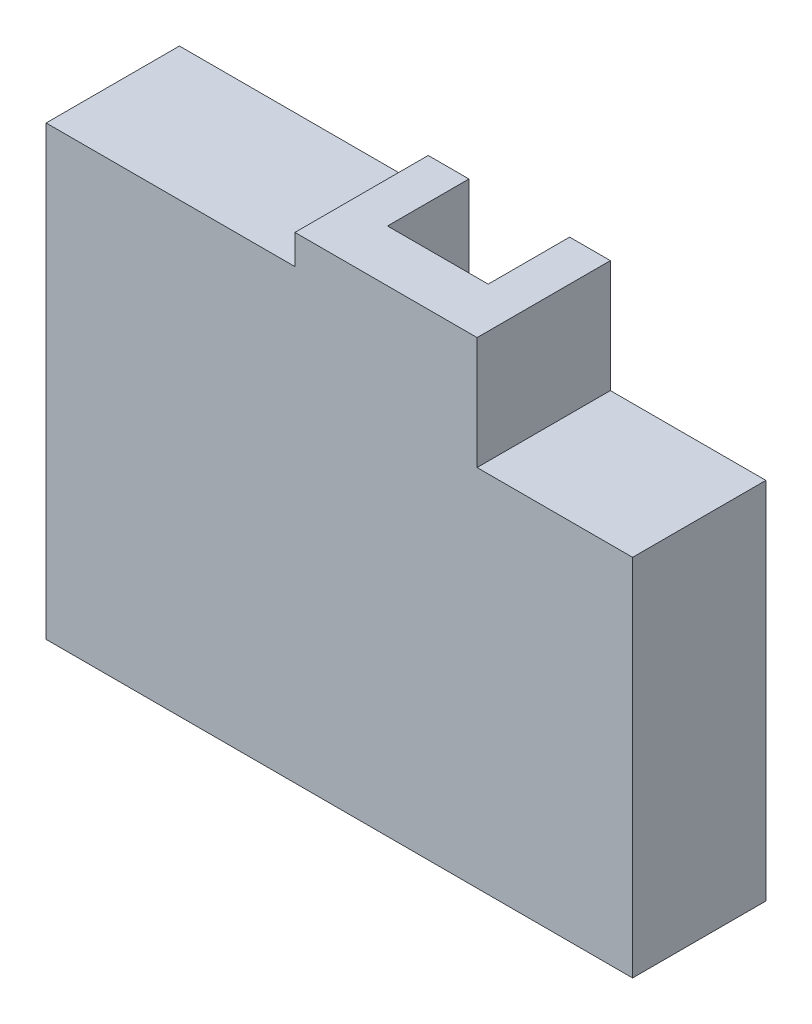
from build123d import *

# Parameters (mm, degrees)
BOSS_EXTRUDE3_DEPTH = 3
BOSS_EXTRUDE4_DEPTH = 15
CUT_EXTRUDE1_DEPTH  = 3
CUT_EXTRUDE2_DEPTH  = 3
SKETCH4_W           = 13.6
SKETCH4_H           = 11
CUT_EXTRUDE3_DEPTH  = 3
CUT_EXTRUDE4_DEPTH  = 3


with BuildPart() as part:
    # Sketch1 → Boss-Extrude3 (new body)
    with BuildSketch(Plane.XY):
        Polygon((0, 0), (79.2, 0), (79.2, 49.2), (58.2, 49.2), (58.2, 64.4), (33.6, 64.4), (33.6, 60.4), (0, 60.4), align=None)
    extrude(amount=BOSS_EXTRUDE3_DEPTH)

    # Sketch1_9 → Boss-Extrude4 (add)
    with BuildSketch(Plane.XY):
        Polygon((0, 0), (79.2, 0), (79.2, 49.2), (58.2, 49.2), (58.2, 64.4), (33.6, 64.4), (33.6, 60.4), (0, 60.4), align=None)
        Polygon((76.2, 3), (3, 3), (3, 57.4), (33.6, 57.4), (33.6, 29), (39.1, 29), (39.1, 61.4), (52.7, 61.4), (52.7, 29), (58.2, 29), (58.2, 46.2), (76.2, 46.2), align=None, mode=Mode.SUBTRACT)
    extrude(amount=-BOSS_EXTRUDE4_DEPTH)

    # Sketch2 → Cut-Extrude1 (cut)
    with BuildSketch(Plane(origin=(0, 0, 0), x_dir=(-1, 0, 0), z_dir=(0, -1, 0))):
        Polygon((0, 0), (0, 15), (-33.6, 15), (-18.6, 0), align=None)
    extrude(amount=-CUT_EXTRUDE1_DEPTH, mode=Mode.SUBTRACT)

    # Sketch3 → Cut-Extrude2 (cut)
    with BuildSketch(Plane.ZY):
        Polygon((0, 3), (-15, 18), (-15, 3), align=None)
    extrude(amount=-CUT_EXTRUDE2_DEPTH, mode=Mode.SUBTRACT)

    # Sketch4 → Cut-Extrude3 (cut)
    with BuildSketch(Plane(origin=(0, 64.4, 0), x_dir=(1, 0, 0), z_dir=(0, 1, 0))):
        with Locations((45.9, 9.5)):
            Rectangle(SKETCH4_W, SKETCH4_H)
    extrude(amount=-CUT_EXTRUDE3_DEPTH, mode=Mode.SUBTRACT)

    # Sketch5 → Cut-Extrude4 (cut)
    with BuildSketch(Plane(origin=(0, 0, 0), x_dir=(-1, 0, 0), z_dir=(0, -1, 0))):
        Polygon((-33.6, 15), (-51.6, 15), (-36.6, 0), (-18.6, 0), align=None)
    extrude(amount=-CUT_EXTRUDE4_DEPTH, mode=Mode.SUBTRACT)


solid = part.part
